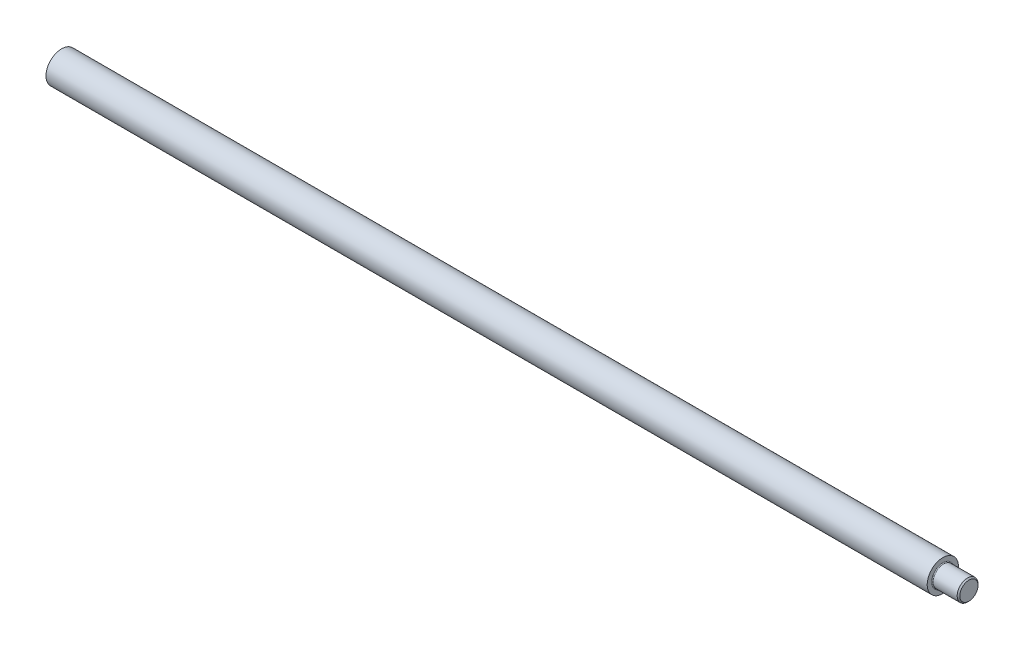
from build123d import *


with BuildPart() as part:
    # Sketch1 → Revolve1 (revolve)
    with BuildSketch(Plane.XY):
        with BuildLine():
            Line((30, 5.684210526), (30, 0))
            Line((30, 0), (360, 0))
            Line((360, 0), (360, 3.315789474))
            Line((360, 3.315789474), (359.526315789, 3.789473684))
            Line((359.526315789, 3.789473684), (350.810526316, 3.789473684))
            ThreePointArc((350.810526316, 3.789473684), (350.609559125, 3.87271702), (350.526315789, 4.073684211))
            Line((350.526315789, 4.073684211), (350.526315789, 5.684210526))
            Line((350.526315789, 5.684210526), (30, 5.684210526))
        make_face()
    revolve(axis=Axis((30, 0, 0), (1, 0, 0)))


solid = part.part
